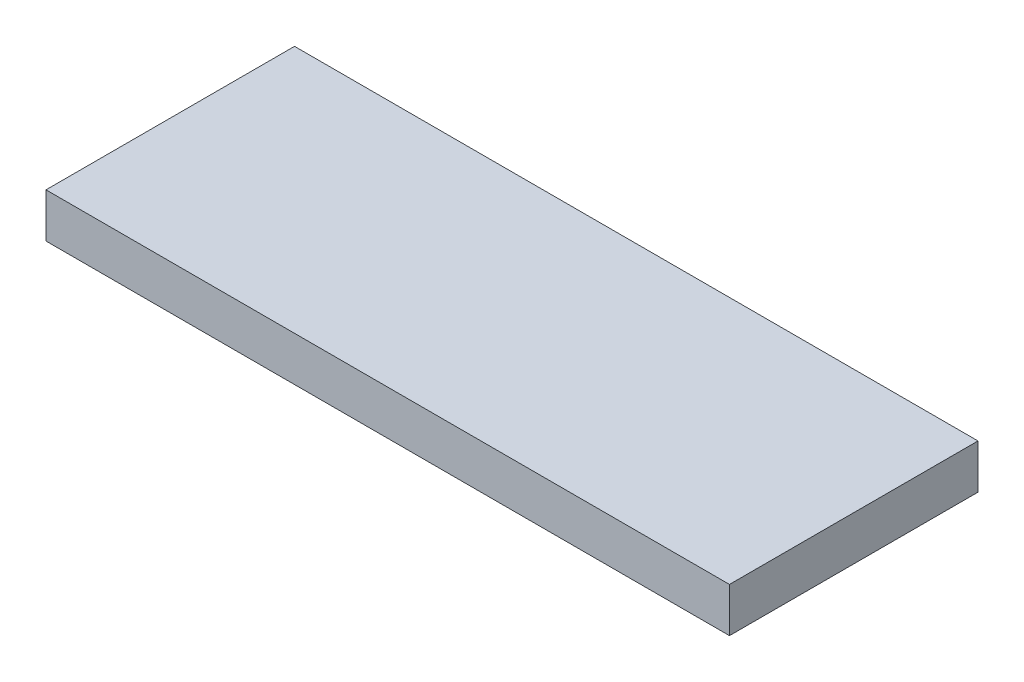
from build123d import *

# Parameters (mm, degrees)
SKETCH1_W  = 154
SKETCH1_H  = 56
BASE_DEPTH = 10


with BuildPart() as part:
    # Sketch1 → base (new body)
    with BuildSketch(Plane(origin=(0, 0, 0), x_dir=(1, 0, 0), z_dir=(0, 1, 0))):
        Rectangle(SKETCH1_W, SKETCH1_H)
    extrude(amount=BASE_DEPTH)

    # Sketch4 → Cut-Revolve1 (revolve, cut)
    with BuildSketch(Plane(origin=(0, 0, 0), x_dir=(0, 0, -1), z_dir=(1, 0, 0))):
        Polygon((3, 0), (3, 2), (0, 3.732050808), (0, 0), align=None)
    revolve(axis=Axis((0, 3.732050808, 0), (0, -1, 0)), mode=Mode.SUBTRACT)


solid = part.part
